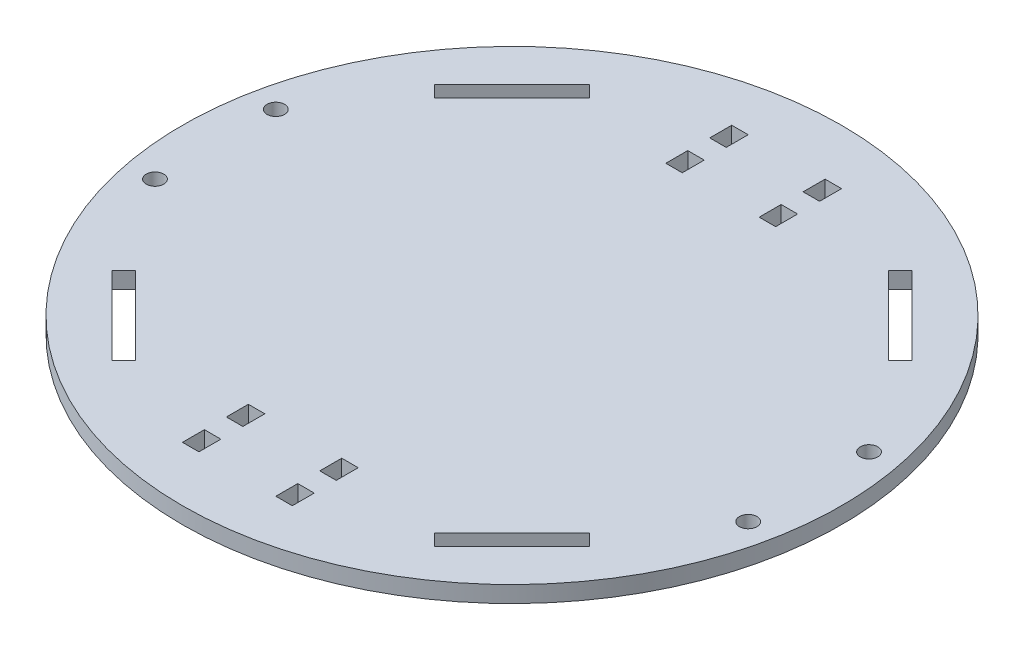
from build123d import *

# Parameters (mm, degrees)
SKETCH1_R               = 60
BOSS_EXTRUDE1_DEPTH     = 1.5
SKETCH2_R               = 1.6
CUT_EXTRUDE1_DEPTH      = 2.5
MIRROR2_COPY_1_SKETCH_R = 1.6
MIRROR2_COPY_1_DEPTH    = 2.5
SKETCH3_W               = 3
SKETCH3_H               = 4
CUT_EXTRUDE2_DEPTH      = 4
LPATTERN1_COUNT         = 2
LPATTERN1_PITCH         = 8
MIRROR3_COPY_1_SKETCH_W = 3
MIRROR3_COPY_1_SKETCH_H = 4
MIRROR3_COPY_1_DEPTH    = 4
MIRROR4_COPY_1_SKETCH_W = 3
MIRROR4_COPY_1_SKETCH_H = 4
MIRROR4_COPY_1_DEPTH    = 4
MIRROR4_COPY_2_SKETCH_W = 3
MIRROR4_COPY_2_SKETCH_H = 4
MIRROR4_COPY_2_DEPTH    = 4
MIRROR4_COPY_3_SKETCH_W = 3
MIRROR4_COPY_3_SKETCH_H = 4
MIRROR4_COPY_3_DEPTH    = 4
CUT_EXTRUDE3_START      = -4
CUT_EXTRUDE3_DEPTH      = 5
CIRPATTERN1_COUNT       = 4


with BuildPart() as part:
    # Sketch1 → Boss-Extrude1 (new body, symmetric)
    with BuildSketch(Plane(origin=(0, 0, 0), x_dir=(1, 0, 0), z_dir=(0, 1, 0))):
        Circle(SKETCH1_R)
    extrude(amount=BOSS_EXTRUDE1_DEPTH, both=True)

    # Sketch2 → Cut-Extrude1 (cut, symmetric)
    with BuildSketch(Plane(origin=(0, 0, 0), x_dir=(1, 0, 0), z_dir=(0, 1, 0))):
        with Locations((54, 11)):
            Circle(SKETCH2_R)
    cut_extrude1 = extrude(amount=CUT_EXTRUDE1_DEPTH, both=True, mode=Mode.SUBTRACT)

    # Mirror1: Cut-Extrude1 across plane
    add(cut_extrude1.mirror(Plane(origin=(0, 0, 0), x_dir=(0, 0, 1), z_dir=(1, 0, 0))), mode=Mode.SUBTRACT)

    # Mirror2: Cut-Extrude1 across plane
    add(cut_extrude1.mirror(Plane.XY), mode=Mode.SUBTRACT)

    # Mirror2 copy 1 sketch → Mirror2 copy 1 (cut, symmetric)
    with BuildSketch(Plane(origin=(0, 0, 0), x_dir=(-1, 0, 0), z_dir=(0, 1, 0))):
        with Locations((54, 11)):
            Circle(MIRROR2_COPY_1_SKETCH_R)
    extrude(amount=MIRROR2_COPY_1_DEPTH, both=True, mode=Mode.SUBTRACT)

    # Sketch3 → Cut-Extrude2 (cut, through all)
    with BuildSketch(Plane(origin=(0, 1.5, 0), x_dir=(1, 0, 0), z_dir=(0, 1, 0))):
        with Locations((-8.5, 48)):
            Rectangle(SKETCH3_W, SKETCH3_H)
    cut_extrude2 = extrude(amount=-CUT_EXTRUDE2_DEPTH, mode=Mode.SUBTRACT)

    # LPattern1: Cut-Extrude2 ×2
    with Locations(*[(0, 0, i * LPATTERN1_PITCH) for i in range(1, LPATTERN1_COUNT)]):
        add(cut_extrude2, mode=Mode.SUBTRACT)

    # Mirror3: Cut-Extrude2 across plane
    add(cut_extrude2.mirror(Plane(origin=(0, 0, 0), x_dir=(0, 0, 1), z_dir=(1, 0, 0))), mode=Mode.SUBTRACT)

    # Mirror3 copy 1 sketch → Mirror3 copy 1 (cut, through all)
    with BuildSketch(Plane(origin=(0, 1.5, 8), x_dir=(-1, 0, 0), z_dir=(0, 1, 0))):
        with Locations((-8.5, -48)):
            Rectangle(MIRROR3_COPY_1_SKETCH_W, MIRROR3_COPY_1_SKETCH_H)
    extrude(amount=-MIRROR3_COPY_1_DEPTH, mode=Mode.SUBTRACT)

    # Mirror4: Cut-Extrude2 across plane
    add(cut_extrude2.mirror(Plane.XY), mode=Mode.SUBTRACT)

    # Mirror4 copy 1 sketch → Mirror4 copy 1 (cut, through all)
    with BuildSketch(Plane(origin=(0, 1.5, 0), x_dir=(-1, 0, 0), z_dir=(0, 1, 0))):
        with Locations((-8.5, 48)):
            Rectangle(MIRROR4_COPY_1_SKETCH_W, MIRROR4_COPY_1_SKETCH_H)
    extrude(amount=-MIRROR4_COPY_1_DEPTH, mode=Mode.SUBTRACT)

    # Mirror4 copy 2 sketch → Mirror4 copy 2 (cut, through all)
    with BuildSketch(Plane(origin=(0, 1.5, -8), x_dir=(-1, 0, 0), z_dir=(0, 1, 0))):
        with Locations((-8.5, 48)):
            Rectangle(MIRROR4_COPY_2_SKETCH_W, MIRROR4_COPY_2_SKETCH_H)
    extrude(amount=-MIRROR4_COPY_2_DEPTH, mode=Mode.SUBTRACT)

    # Mirror4 copy 3 sketch → Mirror4 copy 3 (cut, through all)
    with BuildSketch(Plane(origin=(0, 1.5, -8), x_dir=(1, 0, 0), z_dir=(0, 1, 0))):
        with Locations((-8.5, -48)):
            Rectangle(MIRROR4_COPY_3_SKETCH_W, MIRROR4_COPY_3_SKETCH_H)
    extrude(amount=-MIRROR4_COPY_3_DEPTH, mode=Mode.SUBTRACT)

    # Sketch4 → Cut-Extrude3 (cut)
    with BuildSketch(Plane(origin=(0, 1.5, 0), x_dir=(1, 0, 0), z_dir=(0, 1, 0)).offset(CUT_EXTRUDE3_START)):
        Polygon((27.223611076, 41.365746699), (41.365746699, 27.223611076), (43.487067043, 29.344931419), (29.344931419, 43.487067043), align=None)
    cut_extrude3 = extrude(amount=CUT_EXTRUDE3_DEPTH, mode=Mode.SUBTRACT)

    # CirPattern1: Cut-Extrude3 ×4 about axis
    cirpattern1_axis = Axis((0, 0, 0), (0, 1, 0))
    for i in range(1, CIRPATTERN1_COUNT):
        add(cut_extrude3.rotate(cirpattern1_axis, i * 360 / CIRPATTERN1_COUNT), mode=Mode.SUBTRACT)


solid = part.part
